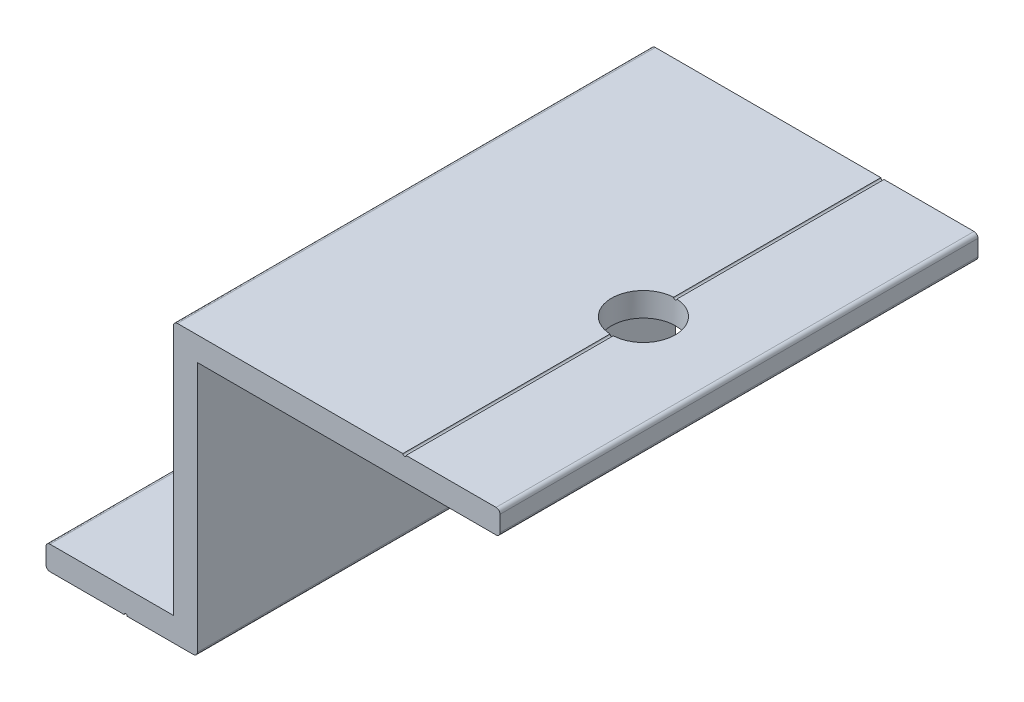
from build123d import *

# Parameters (mm, degrees)
EXTRUDE_1_DEPTH     = 60
SKETCH_2_R          = 4
SKETCH_2_R_2        = 2.1
CUT_EXTRUDE_1_DEPTH = 36
SKETCH_3_R          = 0.2
CUT_EXTRUDE_2_DEPTH = 70
FILLET_1_R          = 0.5


with BuildPart() as part:
    # 草图1 → 凸台-拉伸1 (new body)
    with BuildSketch(Plane.XY):
        Polygon((0, 0), (19, 0), (19, 32), (57, 32), (57, 35), (16, 35), (16, 3), (0, 3), align=None)
    extrude(amount=EXTRUDE_1_DEPTH)

    # 草图2 → 切除-拉伸1 (cut, through all)
    with BuildSketch(Plane(origin=(0, 35, 0), x_dir=(1, 0, 0), z_dir=(0, 1, 0))):
        with Locations((45, -30)):
            Circle(SKETCH_2_R)
        with Locations((10, -30)):
            Circle(SKETCH_2_R_2)
        with Locations((10, -50)):
            Circle(SKETCH_2_R_2)
        with Locations((10, -10)):
            Circle(SKETCH_2_R_2)
    extrude(amount=-CUT_EXTRUDE_1_DEPTH, mode=Mode.SUBTRACT)

    # 草图3 → 切除-拉伸2 (cut)
    with BuildSketch(Plane.XY.offset(60)):
        with Locations((10, 0)):
            Circle(SKETCH_3_R)
        with Locations((45, 35)):
            Circle(SKETCH_3_R)
    extrude(amount=-CUT_EXTRUDE_2_DEPTH, mode=Mode.SUBTRACT)

    # 圆角1
    fillet_1_edges = [part.edges().sort_by_distance(p)[0] for p in [
        (0, 3, 30),
        (16, 35, 30),
        (57, 35, 30),
        (57, 32, 30),
        (19, 0, 30),
        (0, 0, 30),
    ]]
    fillet(fillet_1_edges, radius=FILLET_1_R)


solid = part.part
